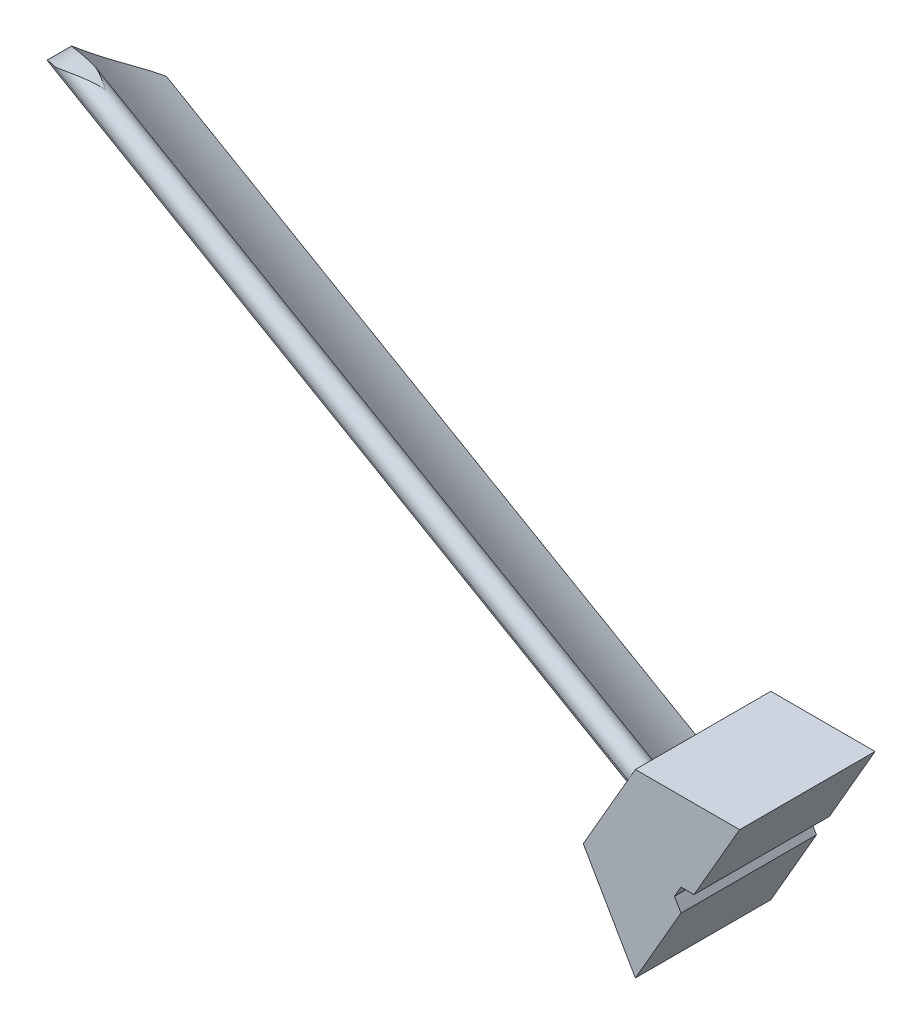
from build123d import *

# Parameters (mm, degrees)
Y_KSEKLIK_EKSTR_ZYON1_DEPTH = 24
Y_KSEKLIK_EKSTR_ZYON3_DEPTH = 120
KES_EKSTR_ZYON1_DEPTH       = 120
KES_EKSTR_ZYON2_DEPTH       = 120


with BuildPart() as part:
    # Çizim1 → Yükseklik-Ekstrüzyon1 (new body)
    with BuildSketch(Plane.XY):
        Polygon((18.475208614, 0), (9.237604307, 16), (-9.237604307, 16), (-18.475208614, 0), (-9.237604307, -16), (9.237604307, -16), align=None)
        Polygon((2.309401077, 0), (1.154700538, 2), (-1.154700538, 2), (-2.309401077, 0), (-1.154700538, -2), (1.154700538, -2), align=None, mode=Mode.SUBTRACT)
    extrude(amount=Y_KSEKLIK_EKSTR_ZYON1_DEPTH)

    # Çizim2 → Yükseklik-Ekstrüzyon3 (add)
    with BuildSketch(Plane(origin=(-13.856406461, 8, 0), x_dir=(0, 0, 1), z_dir=(-0.866025404, 0.5, 0))):
        with BuildLine():
            ThreePointArc((20.566689436, 8.632459435), (12.282851611, -2.425053991), (0.070057864, -8.885567992))
            ThreePointArc((0.070057864, -8.885567992), (0, -9.037604307), (0.070057864, -9.189640622))
            ThreePointArc((0.070057864, -9.189640622), (13.640166109, -4.672052834), (23.386017658, 5.795746113))
            ThreePointArc((23.386017658, 5.795746113), (23.418553761, 8.64746431), (20.566689436, 8.632459435))
        make_face()
    extrude(amount=Y_KSEKLIK_EKSTR_ZYON3_DEPTH)

    # Çizim4 → Kes-Ekstrüzyon1 (cut)
    with BuildSketch(Plane.XY.offset(24)):
        with BuildLine():
            Line((-105.114365337, 71.354096261), (-100.895998051, 78.520414233))
            Line((-100.895998051, 78.520414233), (-120.05269231, 81.506783127))
            Line((-120.05269231, 81.506783127), (-133.968493321, 62.353012073))
            Line((-133.968493321, 62.353012073), (-123.727089206, 47.811781803))
            Line((-123.727089206, 47.811781803), (-114.313260633, 55.388064385))
            ThreePointArc((-114.313260633, 55.388064385), (-117.77159569, 68.013605153), (-105.114365337, 71.354096261))
        make_face()
    extrude(amount=-KES_EKSTR_ZYON1_DEPTH, mode=Mode.SUBTRACT)

    # Çizim5 → Kes-Ekstrüzyon2 (cut)
    with BuildSketch(Plane.XY.offset(24)):
        Polygon((9.237604307, 16), (-9.237604307, -16), (-9.237604307, -28.740421499), (42.199790623, -28.740421499), (42.199790623, 12.667995961), align=None)
    extrude(amount=-KES_EKSTR_ZYON2_DEPTH, mode=Mode.SUBTRACT)


solid = part.part
